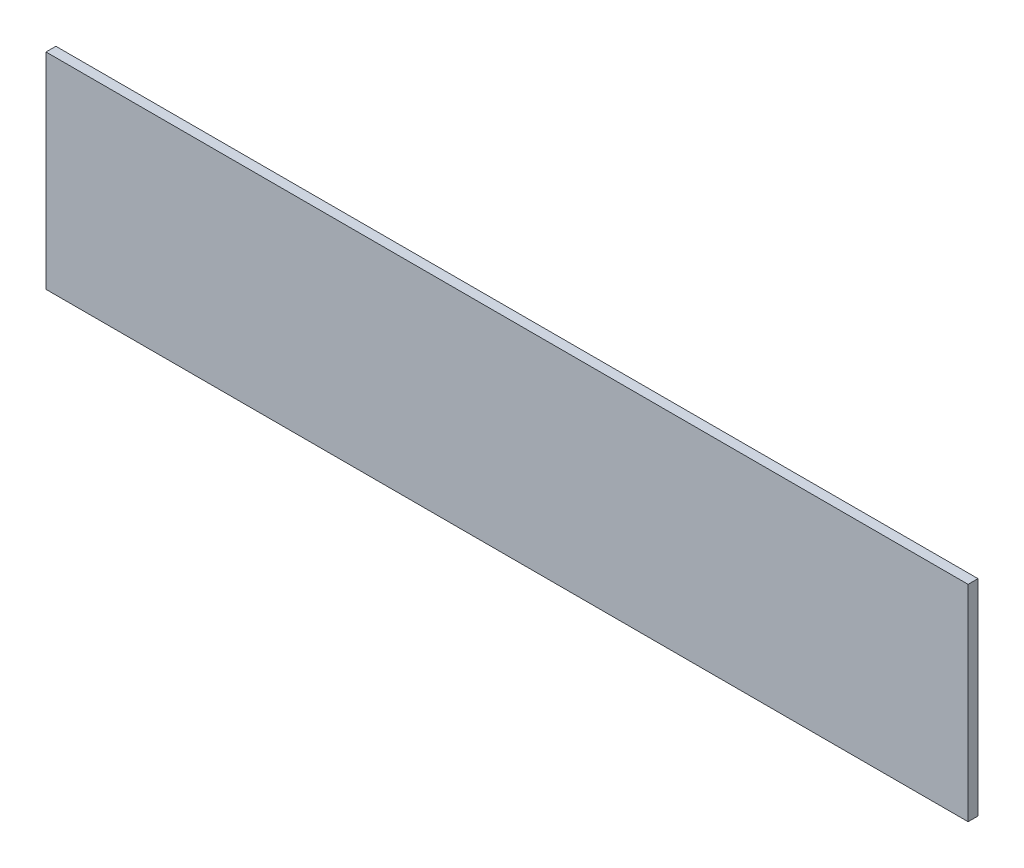
from build123d import *

# Parameters (mm, degrees)
SKETCH1_W           = 592
SKETCH1_H           = 132
BOSS_EXTRUDE1_DEPTH = 6.35


with BuildPart() as part:
    # Sketch1 → Boss-Extrude1 (new body)
    with BuildSketch(Plane.XY):
        with Locations((296, 66)):
            Rectangle(SKETCH1_W, SKETCH1_H)
    extrude(amount=BOSS_EXTRUDE1_DEPTH)


solid = part.part
